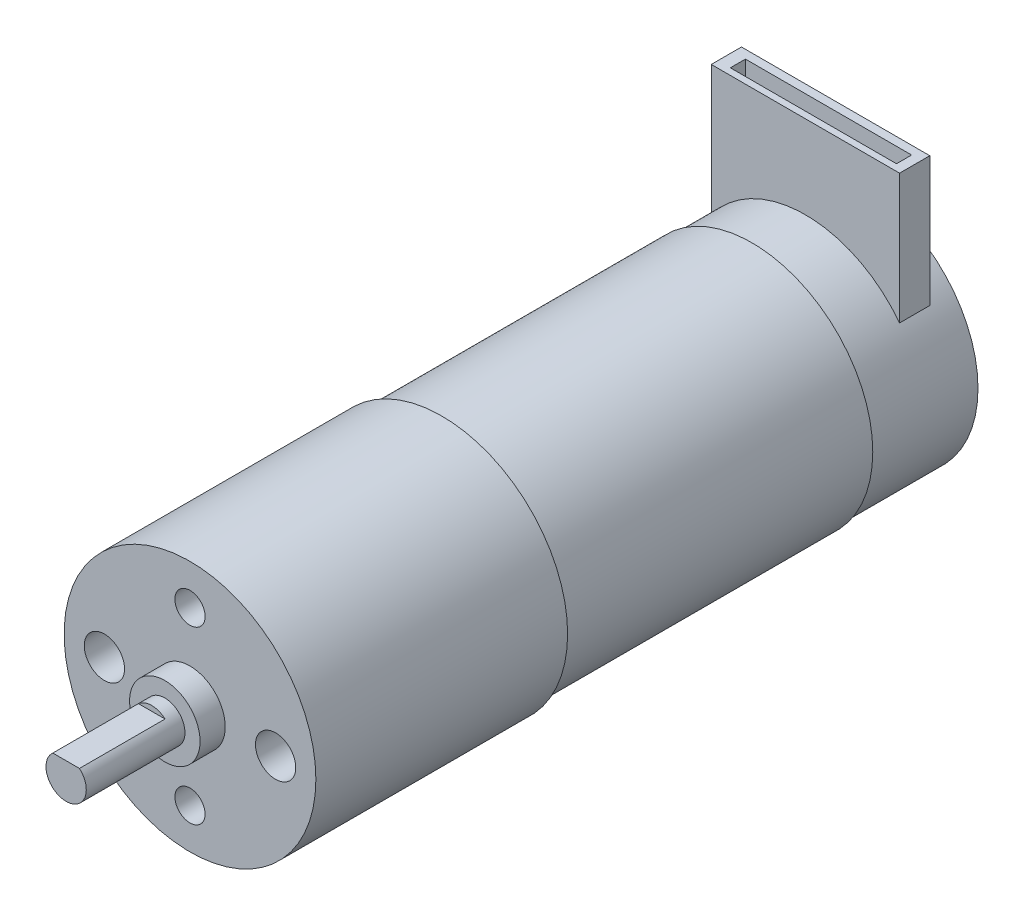
from build123d import *

# Parameters (mm, degrees)
SKETCH1_R           = 12
BOSS_EXTRUDE1_DEPTH = 30.8
SKETCH2_R           = 12.5
BOSS_EXTRUDE2_DEPTH = 25
SKETCH3_R           = 3.5
BOSS_EXTRUDE3_DEPTH = 2.5
SKETCH4_R           = 2
BOSS_EXTRUDE4_DEPTH = 9.8
CUT_EXTRUDE1_DEPTH  = 8.5
SKETCH6_R           = 11.75
BOSS_EXTRUDE5_DEPTH = 10.7
SKETCH7_W           = 18.699432978
SKETCH7_H           = 3
BOSS_EXTRUDE6_DEPTH = 20
SKETCH8_R           = 1.5
CUT_EXTRUDE2_DEPTH  = 10
SKETCH9_R           = 2
CUT_EXTRUDE3_DEPTH  = 10
SKETCH10_W          = 16.5
SKETCH10_H          = 1.5
CUT_EXTRUDE4_DEPTH  = 10


with BuildPart() as part:
    # Sketch1 → Boss-Extrude1 (new body)
    with BuildSketch(Plane.XY):
        Circle(SKETCH1_R)
    extrude(amount=BOSS_EXTRUDE1_DEPTH)

    # Sketch2 → Boss-Extrude2 (add)
    with BuildSketch(Plane.XY.offset(30.8)):
        Circle(SKETCH2_R)
    extrude(amount=BOSS_EXTRUDE2_DEPTH)

    # Sketch3 → Boss-Extrude3 (add)
    with BuildSketch(Plane.XY.offset(55.8)):
        Circle(SKETCH3_R)
    extrude(amount=BOSS_EXTRUDE3_DEPTH)

    # Sketch4 → Boss-Extrude4 (add)
    with BuildSketch(Plane.XY.offset(58.3)):
        Circle(SKETCH4_R)
    extrude(amount=BOSS_EXTRUDE4_DEPTH)

    # Sketch5 → Cut-Extrude1 (cut)
    with BuildSketch(Plane.XY.offset(68.1)):
        with BuildLine():
            Line((-1.322875656, 1.5), (0, 1.5))
            Line((0, 1.5), (1.322875656, 1.5))
            ThreePointArc((1.322875656, 1.5), (0, 2), (-1.322875656, 1.5))
        make_face()
    extrude(amount=-CUT_EXTRUDE1_DEPTH, mode=Mode.SUBTRACT)

    # Sketch6 → Boss-Extrude5 (add)
    with BuildSketch(Plane(origin=(0, 0, 0), x_dir=(-1, 0, 0), z_dir=(0, 0, -1))):
        Circle(SKETCH6_R)
    extrude(amount=BOSS_EXTRUDE5_DEPTH)

    # Sketch7 → Boss-Extrude6 (add)
    with BuildSketch(Plane(origin=(0, 0, 0), x_dir=(1, 0, 0), z_dir=(0, 1, 0))):
        with Locations((0, 6.81237414)):
            Rectangle(SKETCH7_W, SKETCH7_H)
    extrude(amount=BOSS_EXTRUDE6_DEPTH)

    # Sketch8 → Cut-Extrude2 (cut)
    with BuildSketch(Plane.XY.offset(55.8)):
        with Locations((0, -8.5)):
            Circle(SKETCH8_R)
    cut_extrude2 = extrude(amount=-CUT_EXTRUDE2_DEPTH, mode=Mode.SUBTRACT)

    # Mirror1: Cut-Extrude2 across plane
    add(cut_extrude2.mirror(Plane.ZX), mode=Mode.SUBTRACT)

    # Sketch9 → Cut-Extrude3 (cut)
    with BuildSketch(Plane.XY.offset(55.8)):
        with Locations((-8.5, 0)):
            Circle(SKETCH9_R)
    cut_extrude3 = extrude(amount=-CUT_EXTRUDE3_DEPTH, mode=Mode.SUBTRACT)

    # Mirror3: Cut-Extrude3 across plane
    add(cut_extrude3.mirror(Plane(origin=(0, 0, 0), x_dir=(0, 0, 1), z_dir=(1, 0, 0))), mode=Mode.SUBTRACT)

    # Sketch10 → Cut-Extrude4 (cut)
    with BuildSketch(Plane(origin=(0, 20, 0), x_dir=(1, 0, 0), z_dir=(0, 1, 0))):
        with Locations((0.137296408, 6.718389465)):
            Rectangle(SKETCH10_W, SKETCH10_H)
    extrude(amount=-CUT_EXTRUDE4_DEPTH, mode=Mode.SUBTRACT)


solid = part.part
